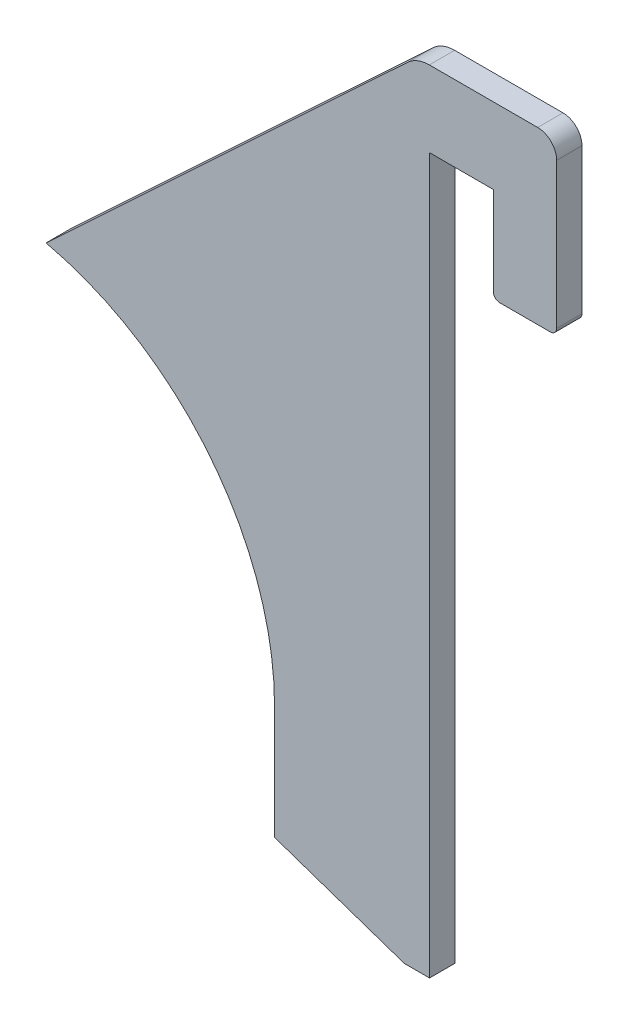
from build123d import *

# Parameters (mm, degrees)
BOSS_EXTRU_1_DEPTH = 4
FILLET1_R          = 5
FILLET1_2_R        = 3
FILLET1_3_R        = 1


with BuildPart() as part:
    # Esquisse1 → Boss.-Extru.1 (new body)
    with BuildSketch(Plane.XY):
        with BuildLine():
            Line((46.5, 0), (46.5, -18))
            Line((46.5, -18), (67, -25))
            Line((67, -25), (71, -25))
            Line((71, -25), (71, 88))
            Line((71, 88), (81.1, 88))
            Line((81.1, 88), (81.1, 73))
            Line((81.1, 73), (91.1, 73))
            Line((91.1, 73), (91.1, 100))
            Line((91.1, 100), (69, 100))
            Line((69, 100), (10.371982926, 45.328489608))
            ThreePointArc((10.371982926, 45.328489608), (36.363080219, 28.982346298), (46.5, 0))
        make_face()
    extrude(amount=BOSS_EXTRU_1_DEPTH)

    # Fillet1
    fillet1_edges = [part.edges().sort_by_distance(p)[0] for p in [
        (69, 100, 2),
    ]]
    fillet(fillet1_edges, radius=FILLET1_R)

    # Fillet1 2
    fillet1_2_edges = [part.edges().sort_by_distance(p)[0] for p in [
        (91.1, 100, 2),
    ]]
    fillet(fillet1_2_edges, radius=FILLET1_2_R)

    # Fillet1 3
    fillet1_3_edges = [part.edges().sort_by_distance(p)[0] for p in [
        (91.1, 73, 2),
        (81.1, 73, 2),
    ]]
    fillet(fillet1_3_edges, radius=FILLET1_3_R)


solid = part.part
